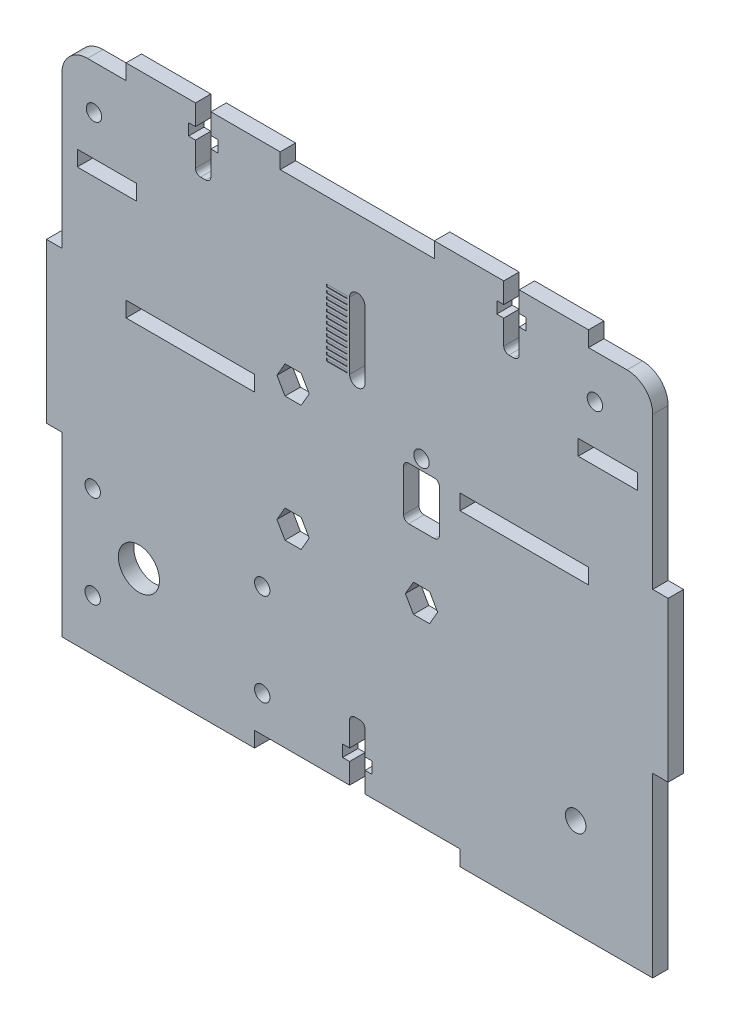
from build123d import *

# Parameters (mm, degrees)
ESBO_O1_W                   = 115
ESBO_O1_H                   = 100
RESSALTO_EXTRUS_O1_DEPTH    = 1.5
ESBO_O2_W                   = 40
ESBO_O2_H                   = 3
ESBO_O2_W_2                 = 25
CORTE_EXTRUS_O1_DEPTH       = 4
ESBO_O3_W                   = 3
ESBO_O3_H                   = 31
ESBO_O3_W_2                 = 30
ESBO_O3_H_2                 = 3
RESSALTO_EXTRUS_O2_DEPTH    = 3
ESBO_O30_R                  = 4
CORTE_EXTRUS_O11_DEPTH      = 1
CORTE_EXTRUS_O11_DEPTH_BACK = 4
ESBO_O31_R                  = 1.5
CORTE_EXTRUS_O12_DEPTH      = 1
CORTE_EXTRUS_O12_DEPTH_BACK = 4
ESBO_O4_R                   = 2
CORTE_EXTRUS_O2_DEPTH       = 4
CUT_EXTRUDE2_DEPTH          = 2.5
CUT_EXTRUDE2_DEPTH_BACK     = 2.5
SKETCH17_R                  = 1.5
SKETCH17_W                  = 11.5
SKETCH17_H                  = 3
CORTE_GY_53LDK_DEPTH        = 2.5
CORTE_GY_53LDK_DEPTH_BACK   = 2.5
CUT_EXTRUDE8_DEPTH          = 2.5
CUT_EXTRUDE8_DEPTH_BACK     = 2.5
SKETCH16_R                  = 1.5
CUT_EXTRUDE12_DEPTH         = 2.5
CUT_EXTRUDE12_DEPTH_BACK    = 2.5
CUT_EXTRUDE9_DEPTH          = 4
FILLET1_R                   = 5
SKETCH12_4_W                = 4
SKETCH12_4_H                = 0.5
CUT_EXTRUDE13_DEPTH         = 0.1


with BuildPart() as part:
    # Esboço1 → Ressalto-extrusão1 (new body, symmetric)
    with BuildSketch(Plane.XY):
        Rectangle(ESBO_O1_W, ESBO_O1_H)
    extrude(amount=RESSALTO_EXTRUS_O1_DEPTH, both=True)

    # Esboço2 → Corte-extrusão1 (cut, through all)
    with BuildSketch(Plane.XY.offset(1.5)):
        with Locations((0, -48.5)):
            Rectangle(ESBO_O2_W, ESBO_O2_H)
        with Locations((-32.5, 11.5)):
            Rectangle(ESBO_O2_W_2, ESBO_O2_H)
        with Locations((32.5, 11.5)):
            Rectangle(ESBO_O2_W_2, ESBO_O2_H)
    extrude(amount=-CORTE_EXTRUS_O1_DEPTH, mode=Mode.SUBTRACT)

    # Esboço3 → Ressalto-extrusão2 (add, through all)
    with BuildSketch(Plane.XY.offset(1.5)):
        with Locations((59, 0)):
            Rectangle(ESBO_O3_W, ESBO_O3_H)
        with Locations((-59, 0)):
            Rectangle(ESBO_O3_W, ESBO_O3_H)
        with Locations((-30, 51.5)):
            Rectangle(ESBO_O3_W_2, ESBO_O3_H_2)
        with Locations((30, 51.5)):
            Rectangle(ESBO_O3_W_2, ESBO_O3_H_2)
    extrude(amount=-RESSALTO_EXTRUS_O2_DEPTH)

    # Esboço30 → Corte-extrusão11 (cut, two sides)
    with BuildSketch(Plane(origin=(0, 0, -1.5), x_dir=(-1, 0, 0), z_dir=(0, 0, -1))) as corte_extrus_o11_sk:
        with Locations((42.5, -31)):
            Circle(ESBO_O30_R)
    extrude(amount=CORTE_EXTRUS_O11_DEPTH, mode=Mode.SUBTRACT)
    extrude(corte_extrus_o11_sk.sketch, amount=-CORTE_EXTRUS_O11_DEPTH_BACK, mode=Mode.SUBTRACT)

    # Esboço31 → Corte-extrusão12 (cut, two sides)
    with BuildSketch(Plane(origin=(0, 0, -1.5), x_dir=(-1, 0, 0), z_dir=(0, 0, -1))) as corte_extrus_o12_sk:
        with Locations((51.5, -22)):
            Circle(ESBO_O31_R)
        with Locations((51.5, -40)):
            Circle(ESBO_O31_R)
        with Locations((18.5, -22)):
            Circle(ESBO_O31_R)
        with Locations((18.5, -40)):
            Circle(ESBO_O31_R)
    extrude(amount=CORTE_EXTRUS_O12_DEPTH, mode=Mode.SUBTRACT)
    extrude(corte_extrus_o12_sk.sketch, amount=-CORTE_EXTRUS_O12_DEPTH_BACK, mode=Mode.SUBTRACT)

    # Esboço4 → Corte-extrusão2 (cut, through all)
    with BuildSketch(Plane.XY.offset(1.5)):
        with Locations((42.5, -31)):
            Circle(ESBO_O4_R)
    extrude(amount=-CORTE_EXTRUS_O2_DEPTH, mode=Mode.SUBTRACT)

    # Sketch5 → Cut-Extrude2 (cut, two sides)
    with BuildSketch(Plane.XY) as cut_extrude2_sk:
        with BuildLine():
            Line((-1.5, -47), (1.5, -47))
            Line((1.5, -47), (1.5, -43))
            Line((1.5, -43), (2.85, -43))
            Line((2.85, -43), (2.85, -40.73))
            Line((2.85, -40.73), (1.5, -40.73))
            Line((1.5, -40.73), (1.5, -36))
            ThreePointArc((1.5, -36), (1.207106781, -35.292893219), (0.5, -35))
            Line((0.5, -35), (-0.5, -35))
            ThreePointArc((-0.5, -35), (-1.207106781, -35.292893219), (-1.5, -36))
            Line((-1.5, -36), (-1.5, -40.73))
            Line((-1.5, -40.73), (-2.85, -40.73))
            Line((-2.85, -40.73), (-2.85, -43))
            Line((-2.85, -43), (-1.5, -43))
            Line((-1.5, -43), (-1.5, -47))
        make_face()
    extrude(amount=CUT_EXTRUDE2_DEPTH, mode=Mode.SUBTRACT)
    extrude(cut_extrude2_sk.sketch, amount=-CUT_EXTRUDE2_DEPTH_BACK, mode=Mode.SUBTRACT)

    # Sketch17 → Corte Gy-53LDK (cut, two sides)
    with BuildSketch(Plane.XY) as corte_gy_53ldk_sk:
        with Locations((-51.25, 41.5)):
            Circle(SKETCH17_R)
        with Locations((46.25, 41.5)):
            Circle(SKETCH17_R)
        with Locations((-48.75, 32.2)):
            Rectangle(SKETCH17_W, SKETCH17_H)
        with Locations((48.75, 32.2)):
            Rectangle(SKETCH17_W, SKETCH17_H)
    extrude(amount=CORTE_GY_53LDK_DEPTH, mode=Mode.SUBTRACT)
    extrude(corte_gy_53ldk_sk.sketch, amount=-CORTE_GY_53LDK_DEPTH_BACK, mode=Mode.SUBTRACT)

    # Sketch11 → Cut-Extrude8 (cut, two sides)
    with BuildSketch(Plane.XY) as cut_extrude8_sk:
        with BuildLine():
            Line((-31.5, 53), (-28.5, 53))
            Line((-28.5, 53), (-28.5, 49))
            Line((-28.5, 49), (-27.15, 49))
            Line((-27.15, 49), (-27.15, 46.73))
            Line((-27.15, 46.73), (-28.5, 46.73))
            Line((-28.5, 46.73), (-28.5, 42))
            ThreePointArc((-28.5, 42), (-28.792893219, 41.292893219), (-29.5, 41))
            Line((-29.5, 41), (-30.5, 41))
            ThreePointArc((-30.5, 41), (-31.207106781, 41.292893219), (-31.5, 42))
            Line((-31.5, 42), (-31.5, 46.73))
            Line((-31.5, 46.73), (-32.85, 46.73))
            Line((-32.85, 46.73), (-32.85, 49))
            Line((-32.85, 49), (-31.5, 49))
            Line((-31.5, 49), (-31.5, 53))
        make_face()
        with BuildLine():
            Line((28.5, 46.73), (27.15, 46.73))
            Line((27.15, 46.73), (27.15, 49))
            Line((27.15, 49), (28.5, 49))
            Line((28.5, 49), (28.5, 53))
            Line((28.5, 53), (31.5, 53))
            Line((31.5, 53), (31.5, 49))
            Line((31.5, 49), (32.85, 49))
            Line((32.85, 49), (32.85, 46.73))
            Line((32.85, 46.73), (31.5, 46.73))
            Line((31.5, 46.73), (31.5, 42))
            ThreePointArc((31.5, 42), (31.207106781, 41.292893219), (30.5, 41))
            Line((30.5, 41), (29.5, 41))
            ThreePointArc((29.5, 41), (28.792893219, 41.292893219), (28.5, 42))
            Line((28.5, 42), (28.5, 46.73))
        make_face()
    extrude(amount=CUT_EXTRUDE8_DEPTH, mode=Mode.SUBTRACT)
    extrude(cut_extrude8_sk.sketch, amount=-CUT_EXTRUDE8_DEPTH_BACK, mode=Mode.SUBTRACT)

    # Sketch16 → Cut-Extrude12 (cut, two sides)
    with BuildSketch(Plane.XY) as cut_extrude12_sk:
        with Locations((12.5, 15.019319768)):
            Circle(SKETCH16_R)
        Polygon((15.64, -9.280680232), (14.07, -6.561360464), (10.93, -6.561360464), (9.36, -9.280680232), (10.93, -12), (14.07, -12), align=None)
        with BuildLine():
            Line((10, 13.019319768), (15, 13.019319768))
            ThreePointArc((15, 13.019319768), (15.707106781, 12.726426549), (16, 12.019319768))
            Line((16, 12.019319768), (16, 3.819319768))
            ThreePointArc((16, 3.819319768), (15.707106781, 3.112212987), (15, 2.819319768))
            Line((15, 2.819319768), (10, 2.819319768))
            ThreePointArc((10, 2.819319768), (9.292893219, 3.112212987), (9, 3.819319768))
            Line((9, 3.819319768), (9, 12.019319768))
            ThreePointArc((9, 12.019319768), (9.292893219, 12.726426549), (10, 13.019319768))
        make_face()
        Polygon((-9.36, 15.019319768), (-10.93, 17.738639536), (-14.07, 17.738639536), (-15.64, 15.019319768), (-14.07, 12.3), (-10.93, 12.3), align=None)
        Polygon((-9.36, -9.280680232), (-10.93, -6.561360464), (-14.07, -6.561360464), (-15.64, -9.280680232), (-14.07, -12), (-10.93, -12), align=None)
    extrude(amount=CUT_EXTRUDE12_DEPTH, mode=Mode.SUBTRACT)
    extrude(cut_extrude12_sk.sketch, amount=-CUT_EXTRUDE12_DEPTH_BACK, mode=Mode.SUBTRACT)

    # Sketch12 → Cut-Extrude9 (cut, through all)
    with BuildSketch(Plane.XY.offset(1.5)):
        with BuildLine():
            Line((1.5, 22.238639536), (1.5, 35.238639536))
            ThreePointArc((1.5, 35.238639536), (0, 36.738639536), (-1.5, 35.238639536))
            Line((-1.5, 35.238639536), (-1.5, 22.238639536))
            ThreePointArc((-1.5, 22.238639536), (0, 20.738639536), (1.5, 22.238639536))
        make_face()
        with BuildLine():
            ThreePointArc((1.5, 35.238639536), (0, 36.738639536), (-1.5, 35.238639536))
            Line((-1.5, 35.238639536), (-1.5, 22.238639536))
            ThreePointArc((-1.5, 22.238639536), (0, 20.738639536), (1.5, 22.238639536))
            Line((1.5, 22.238639536), (1.5, 35.238639536))
        make_face()
    extrude(amount=-CUT_EXTRUDE9_DEPTH, mode=Mode.SUBTRACT)

    # Fillet1
    fillet1_edges = [part.edges().sort_by_distance(p)[0] for p in [
        (-57.5, 50, 0),
        (57.5, 50, 0),
    ]]
    fillet(fillet1_edges, radius=FILLET1_R)

    # Sketch12_4 → Cut-Extrude13 (cut)
    with BuildSketch(Plane.XY.offset(1.5)):
        with Locations((-4, 33.946972869)):
            Rectangle(SKETCH12_4_W, SKETCH12_4_H)
        with Locations((-4, 32.905306202)):
            Rectangle(SKETCH12_4_W, SKETCH12_4_H)
        with Locations((-4, 30.821972869)):
            Rectangle(SKETCH12_4_W, SKETCH12_4_H)
        with Locations((-4, 29.780306202)):
            Rectangle(SKETCH12_4_W, SKETCH12_4_H)
        with Locations((-4, 26.655306202)):
            Rectangle(SKETCH12_4_W, SKETCH12_4_H)
        with Locations((-4, 24.571972869)):
            Rectangle(SKETCH12_4_W, SKETCH12_4_H)
        with Locations((-4, 34.988639536)):
            Rectangle(SKETCH12_4_W, SKETCH12_4_H)
        with Locations((-4, 31.863639536)):
            Rectangle(SKETCH12_4_W, SKETCH12_4_H)
        with Locations((-4, 28.738639536)):
            Rectangle(SKETCH12_4_W, SKETCH12_4_H)
        with Locations((-4, 27.696972869)):
            Rectangle(SKETCH12_4_W, SKETCH12_4_H)
        with Locations((-4, 25.613639536)):
            Rectangle(SKETCH12_4_W, SKETCH12_4_H)
        with Locations((-4, 23.530306202)):
            Rectangle(SKETCH12_4_W, SKETCH12_4_H)
        with Locations((-4, 22.488639536)):
            Rectangle(SKETCH12_4_W, SKETCH12_4_H)
    extrude(amount=-CUT_EXTRUDE13_DEPTH, mode=Mode.SUBTRACT)


solid = part.part
